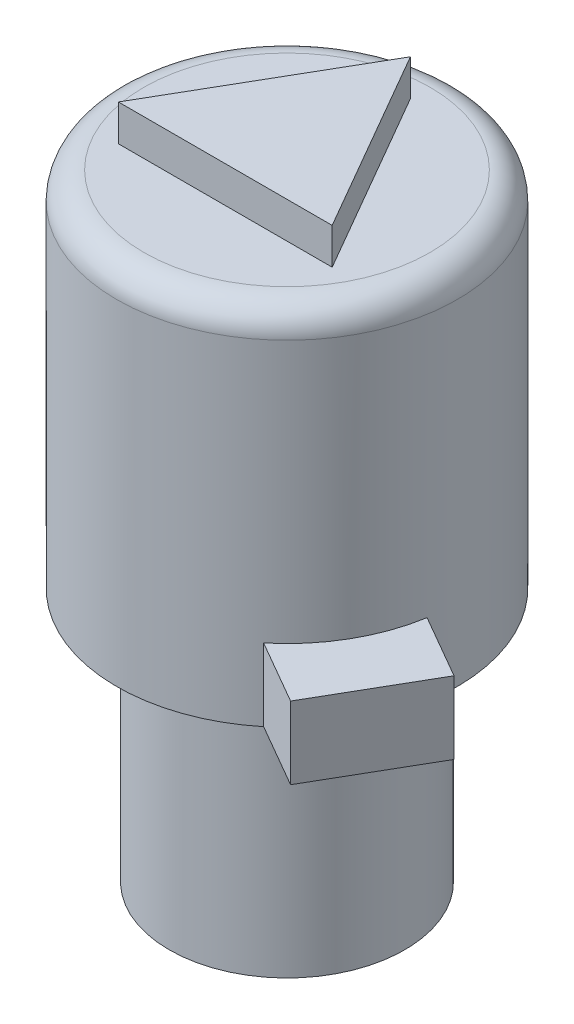
from build123d import *

# Parameters (mm, degrees)
SKETCH1_R           = 3.25
BOSS_EXTRUDE1_DEPTH = 7.018
SKETCH6_R           = 4.7
BOSS_EXTRUDE2_DEPTH = 10
BOSS_EXTRUDE5_DEPTH = 1
FILLET1_R           = 0.75
BOSS_EXTRUDE6_DEPTH = 2


with BuildPart() as part:
    # Sketch1 → Boss-Extrude1 (new body)
    with BuildSketch(Plane(origin=(0, 0, 0), x_dir=(1, 0, 0), z_dir=(0, 1, 0))):
        Circle(SKETCH1_R)
    extrude(amount=BOSS_EXTRUDE1_DEPTH)

    # Sketch6 → Boss-Extrude2 (add)
    with BuildSketch(Plane(origin=(0, 7.018, 0), x_dir=(1, 0, 0), z_dir=(0, 1, 0))):
        Circle(SKETCH6_R)
    extrude(amount=BOSS_EXTRUDE2_DEPTH)

    # Sketch7 → Boss-Extrude5 (add)
    with BuildSketch(Plane(origin=(0, 17.018, 0), x_dir=(1, 0, 0), z_dir=(0, 1, 0))):
        Polygon((2.95, -1.703183294), (0, 3.406366588), (-2.95, -1.703183294), align=None)
    extrude(amount=BOSS_EXTRUDE5_DEPTH)

    # Fillet1
    fillet1_edges = [part.edges().sort_by_distance(p)[0] for p in [
        (-4.7, 17.018, 0),
    ]]
    fillet(fillet1_edges, radius=FILLET1_R)

    # Sketch8 → Boss-Extrude6 (add)
    with BuildSketch(Plane.XZ.offset(-7.018)):
        with BuildLine():
            Line((-4.482079516, -1.414554068), (-6.241843137, -2.430554068))
            Line((-6.241843137, -2.430554068), (-5.225843137, -4.190317689))
            Line((-5.225843137, -4.190317689), (-3.466079516, -3.174317689))
            ThreePointArc((-3.466079516, -3.174317689), (-4.070319398, -2.35), (-4.482079516, -1.414554068))
        make_face()
        with BuildLine():
            Line((2.985424986, 3.630046508), (4.745188607, 4.646046508))
            Line((4.745188607, 4.646046508), (6.396188607, 1.786430625))
            Line((6.396188607, 1.786430625), (4.636424986, 0.770430625))
            ThreePointArc((4.636424986, 0.770430625), (4.070319398, 2.35), (2.985424986, 3.630046508))
        make_face()
    extrude(amount=-BOSS_EXTRUDE6_DEPTH)


solid = part.part
